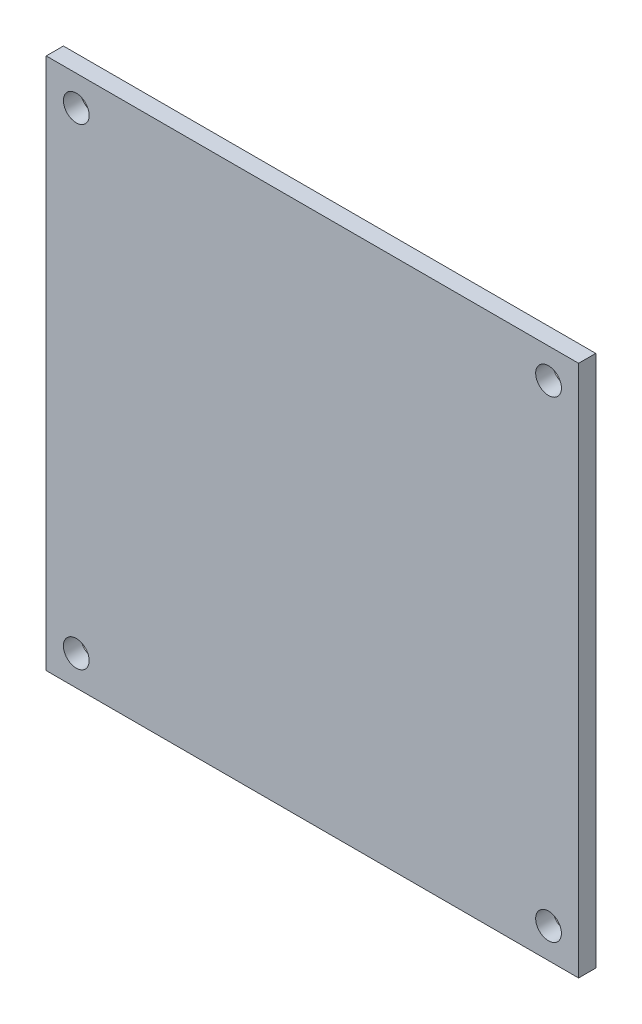
from build123d import *

# Parameters (mm, degrees)
CROQUIS1_W              = 62
CROQUIS1_H              = 62
CROQUIS1_R              = 1.5
SALIENTE_EXTRUIR1_DEPTH = 2
CROQUIS2_W              = 6
CROQUIS2_H              = 23
CROQUIS2_W_2            = 2
CROQUIS2_H_2            = 20.5
SALIENTE_EXTRUIR2_DEPTH = 10


with BuildPart() as part:
    # Croquis1 → Saliente-Extruir1 (new body)
    with BuildSketch(Plane.XY):
        with Locations((-58.141884519, -0.511173184)):
            Rectangle(CROQUIS1_W, CROQUIS1_H)
        with Locations((-85.641884519, 26.988826816)):
            Circle(CROQUIS1_R, mode=Mode.SUBTRACT)
        with Locations((-30.641884519, 26.988826816)):
            Circle(CROQUIS1_R, mode=Mode.SUBTRACT)
        with Locations((-30.641884519, -28.011173184)):
            Circle(CROQUIS1_R, mode=Mode.SUBTRACT)
        with Locations((-85.641884519, -28.011173184)):
            Circle(CROQUIS1_R, mode=Mode.SUBTRACT)
    extrude(amount=SALIENTE_EXTRUIR1_DEPTH)

    # Croquis2 → Saliente-Extruir2 (add)
    with BuildSketch(Plane(origin=(0, 0, 0), x_dir=(-1, 0, 0), z_dir=(0, 0, -1))):
        with Locations((81.141884519, -0.511173184)):
            Rectangle(CROQUIS2_W, CROQUIS2_H)
        with Locations((81.141884519, -0.511173184)):
            Rectangle(CROQUIS2_W_2, CROQUIS2_H_2, mode=Mode.SUBTRACT)
    extrude(amount=SALIENTE_EXTRUIR2_DEPTH)


solid = part.part
